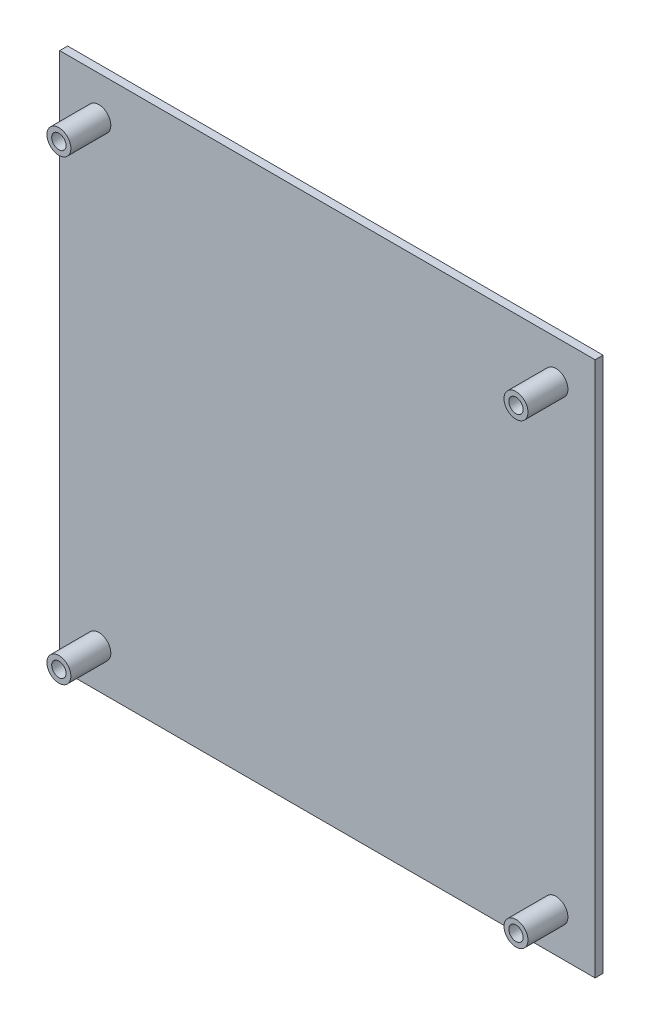
from build123d import *

# Parameters (mm, degrees)
ESQUISSE1_W             = 134
ESQUISSE1_H             = 134
BOSS_EXTRU_1_DEPTH      = 5
ESQUISSE5_W             = 134
ESQUISSE5_H             = 134
ESQUISSE5_W_2           = 126
ESQUISSE5_H_2           = 126
ENL_V_MAT_EXTRU_1_DEPTH = 3
ESQUISSE6_R             = 1.8
ENL_V_MAT_EXTRU_2_DEPTH = 6
ESQUISSE7_R             = 3
ESQUISSE7_R_2           = 1.8
BOSS_EXTRU_2_DEPTH      = 15
ESQUISSE8_R             = 3
ESQUISSE8_R_2           = 1.8
BOSS_EXTRU_3_DEPTH      = 15
ESQUISSE9_R             = 3
ESQUISSE9_R_2           = 1.8
BOSS_EXTRU_6_DEPTH      = 15
ESQUISSE10_R            = 3
ESQUISSE10_R_2          = 1.8
BOSS_EXTRU_7_DEPTH      = 15


with BuildPart() as part:
    # Esquisse1 → Boss.-Extru.1 (new body)
    with BuildSketch(Plane.XY):
        Rectangle(ESQUISSE1_W, ESQUISSE1_H)
    extrude(amount=BOSS_EXTRU_1_DEPTH)

    # Esquisse5 → Enlèv. mat.-Extru.1 (cut)
    with BuildSketch(Plane.XY):
        Rectangle(ESQUISSE5_W, ESQUISSE5_H)
        Rectangle(ESQUISSE5_W_2, ESQUISSE5_H_2, mode=Mode.SUBTRACT)
    extrude(amount=ENL_V_MAT_EXTRU_1_DEPTH, mode=Mode.SUBTRACT)

    # Esquisse6 → Enlèv. mat.-Extru.2 (cut)
    with BuildSketch(Plane.XY):
        with Locations((57.2, 57.2)):
            Circle(ESQUISSE6_R)
        with Locations((57.2, -57.2)):
            Circle(ESQUISSE6_R)
        with Locations((-57.2, -57.2)):
            Circle(ESQUISSE6_R)
        with Locations((-57.2, 57.2)):
            Circle(ESQUISSE6_R)
    extrude(amount=ENL_V_MAT_EXTRU_2_DEPTH, mode=Mode.SUBTRACT)

    # Esquisse7 → Boss.-Extru.2 (add)
    with BuildSketch(Plane.XY):
        with Locations((57.2, 57.2)):
            Circle(ESQUISSE7_R)
        with Locations((57.2, 57.2)):
            Circle(ESQUISSE7_R_2, mode=Mode.SUBTRACT)
    extrude(amount=BOSS_EXTRU_2_DEPTH)

    # Esquisse8 → Boss.-Extru.3 (add)
    with BuildSketch(Plane.XY):
        with Locations((-57.2, 57.2)):
            Circle(ESQUISSE8_R)
        with Locations((-57.2, 57.2)):
            Circle(ESQUISSE8_R_2, mode=Mode.SUBTRACT)
    extrude(amount=BOSS_EXTRU_3_DEPTH)

    # Esquisse9 → Boss.-Extru.6 (add)
    with BuildSketch(Plane.XY):
        with Locations((-57.2, -57.2)):
            Circle(ESQUISSE9_R)
        with Locations((-57.2, -57.2)):
            Circle(ESQUISSE9_R_2, mode=Mode.SUBTRACT)
    extrude(amount=BOSS_EXTRU_6_DEPTH)

    # Esquisse10 → Boss.-Extru.7 (add)
    with BuildSketch(Plane.XY):
        with Locations((57.2, -57.2)):
            Circle(ESQUISSE10_R)
        with Locations((57.2, -57.2)):
            Circle(ESQUISSE10_R_2, mode=Mode.SUBTRACT)
    extrude(amount=BOSS_EXTRU_7_DEPTH)


solid = part.part
